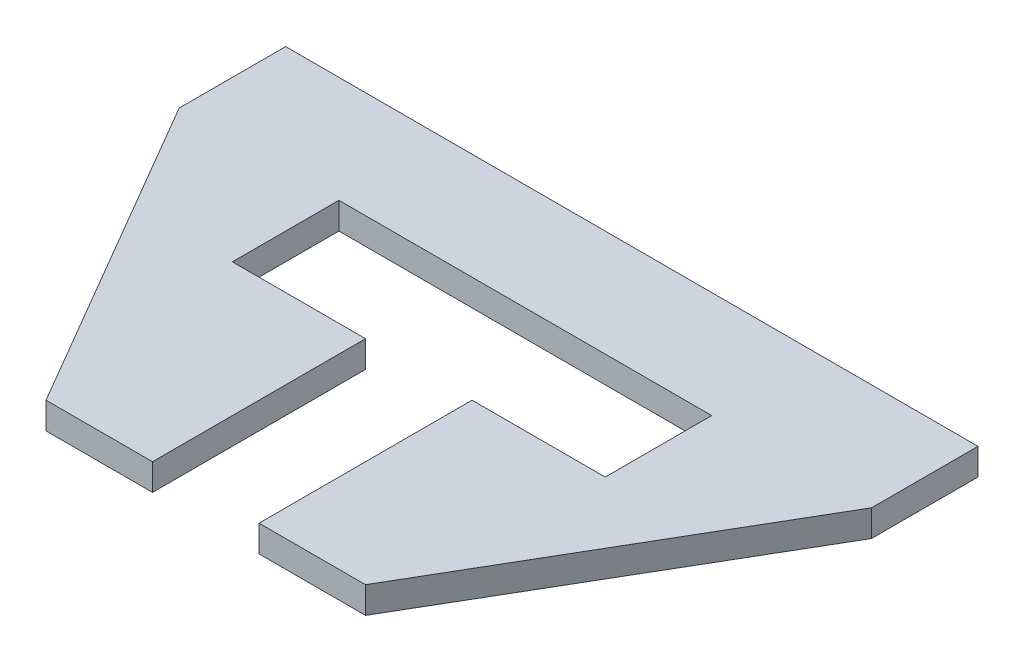
from build123d import *

# Parameters (mm, degrees)
SKETCH2_W           = 165.1
SKETCH2_H           = 101.6
BOSS_EXTRUDE1_DEPTH = 6.35
SKETCH3_W           = 25.4
SKETCH3_H           = 76.2
CUT_EXTRUDE2_DEPTH  = 7.35
SKETCH5_W           = 88.9
SKETCH5_H           = 25.4
CUT_EXTRUDE3_DEPTH  = 7.35
CUT_EXTRUDE4_DEPTH  = 7.35
CUT_EXTRUDE5_DEPTH  = 7.35


with BuildPart() as part:
    # Sketch2 → Boss-Extrude1 (new body)
    with BuildSketch(Plane(origin=(0, 0, 0), x_dir=(1, 0, 0), z_dir=(0, 1, 0))):
        with Locations((-70.660638298, 22.292553191)):
            Rectangle(SKETCH2_W, SKETCH2_H)
    extrude(amount=BOSS_EXTRUDE1_DEPTH)

    # Sketch3 → Cut-Extrude2 (cut, through all)
    with BuildSketch(Plane(origin=(0, 6.35, 0), x_dir=(1, 0, 0), z_dir=(0, 1, 0))):
        with Locations((-70.660638298, 9.592553191)):
            Rectangle(SKETCH3_W, SKETCH3_H)
    extrude(amount=-CUT_EXTRUDE2_DEPTH, mode=Mode.SUBTRACT)

    # Sketch5 → Cut-Extrude3 (cut, through all)
    with BuildSketch(Plane(origin=(0, 6.35, 0), x_dir=(1, 0, 0), z_dir=(0, 1, 0))):
        with Locations((-70.660638298, 34.992553191)):
            Rectangle(SKETCH5_W, SKETCH5_H)
    extrude(amount=-CUT_EXTRUDE3_DEPTH, mode=Mode.SUBTRACT)

    # Sketch6 → Cut-Extrude4 (cut, through all)
    with BuildSketch(Plane(origin=(0, 6.35, 0), x_dir=(1, 0, 0), z_dir=(0, 1, 0))):
        Polygon((-153.210638298, -28.507446809), (-108.760638298, -28.507446809), (-153.210638298, 47.692553191), align=None)
    extrude(amount=-CUT_EXTRUDE4_DEPTH, mode=Mode.SUBTRACT)

    # Sketch7 → Cut-Extrude5 (cut, through all)
    with BuildSketch(Plane(origin=(0, 6.35, 0), x_dir=(1, 0, 0), z_dir=(0, 1, 0))):
        Polygon((11.889361702, -28.507446809), (11.889361702, 47.692553191), (-32.560638298, -28.507446809), align=None)
    extrude(amount=-CUT_EXTRUDE5_DEPTH, mode=Mode.SUBTRACT)


solid = part.part
